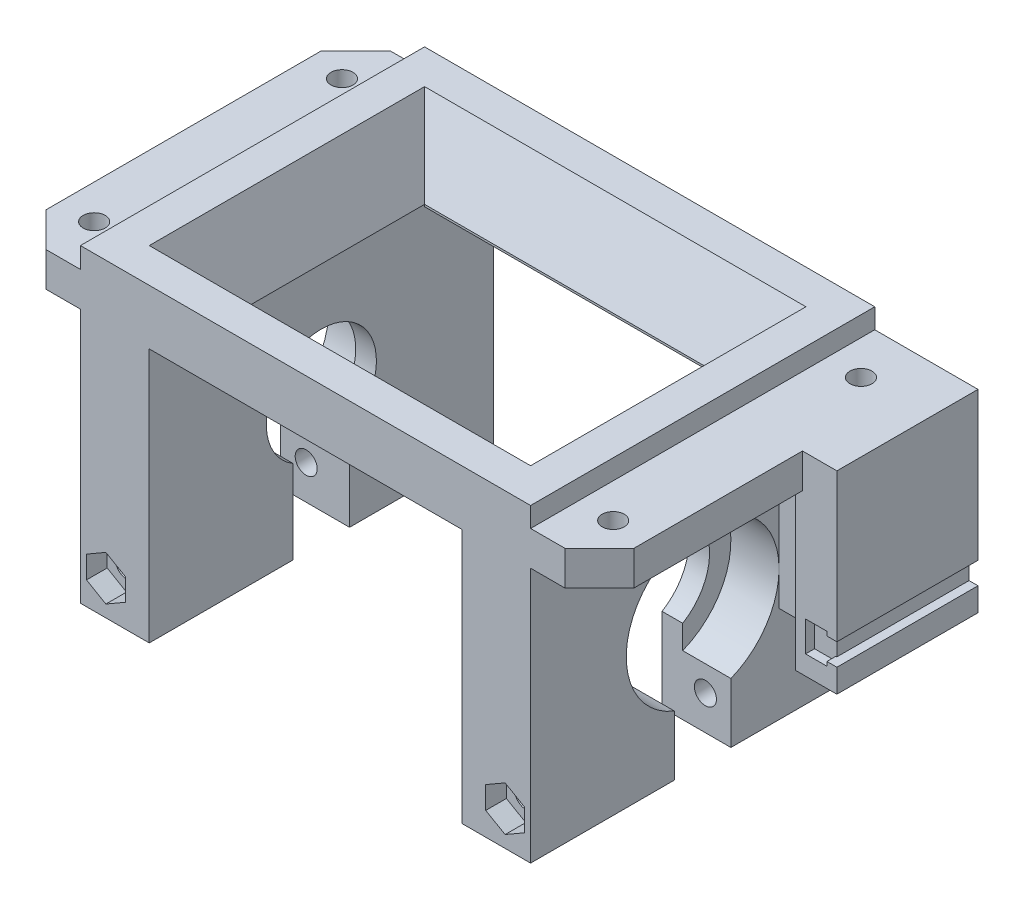
from build123d import *

# Parameters (mm, degrees)
SKETCH1_W           = 65.4
SKETCH1_H           = 60
SKETCH1_W_2         = 45.4
SKETCH1_H_2         = 30
BOSS_EXTRUDE1_DEPTH = 40
SKETCH2_R           = 8
CUT_EXTRUDE1_DEPTH  = 66.4
SKETCH3_W           = 45.4
SKETCH3_H           = 52
CUT_EXTRUDE2_DEPTH  = 37
CHAMFER1_SIZE       = 5
CHAMFER1_SIZE2      = 2.886751346
SKETCH7_W           = 65.4
SKETCH7_H           = 5
CUT_EXTRUDE5_DEPTH  = 41
CHAMFER2_SIZE       = 3
CHAMFER2_SIZE2      = 2.701212133
SKETCH8_W           = 65.4
SKETCH8_H           = 55
SKETCH8_W_2         = 45.4
SKETCH8_H_2         = 30
BOSS_EXTRUDE2_DEPTH = 10
CHAMFER3_SIZE       = 5
CHAMFER3_SIZE2      = 9.813052528
SKETCH10_R          = 11.1
CUT_EXTRUDE8_DEPTH  = 7
SKETCH11_R          = 11.1
CUT_EXTRUDE9_DEPTH  = 7
SKETCH12_W          = 65.4
SKETCH12_H          = 8.2
CUT_EXTRUDE10_DEPTH = 20
SKETCH13_W          = 65.4
SKETCH13_H          = 5
CUT_EXTRUDE11_DEPTH = 3
CHAMFER4_SIZE       = 5
SKETCH20_W          = 50
SKETCH20_H          = 5
BOSS_EXTRUDE5_DEPTH = 10
SKETCH21_W          = 50
SKETCH21_H          = 5
BOSS_EXTRUDE6_DEPTH = 10
CHAMFER5_SIZE       = 5
SKETCH23_R          = 1.6
CUT_EXTRUDE15_DEPTH = 48
SKETCH24_W          = 13.9
SKETCH24_H          = 10
BOSS_EXTRUDE7_DEPTH = 15
SKETCH22_R          = 1.6
CUT_EXTRUDE14_DEPTH = 48.107149008
SKETCH25_R          = 3.5
CUT_EXTRUDE16_DEPTH = 10
SKETCH27_W          = 6
SKETCH27_H          = 10
BOSS_EXTRUDE8_DEPTH = 6.6
CUT_EXTRUDE18_DEPTH = 1.3
SKETCH29_W          = 19.2
SKETCH29_H          = 3.2
CUT_EXTRUDE19_DEPTH = 1.3
SKETCH30_R          = 1.6
CUT_EXTRUDE20_DEPTH = 56
CUT_EXTRUDE21_DEPTH = 3
SKETCH32_R          = 3.15
CUT_EXTRUDE22_DEPTH = 5
SKETCH35_W          = 105.7739029
SKETCH35_H          = 101.810214422
CUT_EXTRUDE23_DEPTH = 5
CHAMFER6_SIZE       = 5
CUT_EXTRUDE25_DEPTH = 43
SKETCH37_R          = 3.5
BOSS_EXTRUDE9_DEPTH = 18.107149


with BuildPart() as part:
    # Sketch1 → Boss-Extrude1 (new body)
    with BuildSketch(Plane(origin=(0, 0, 0), x_dir=(1, 0, 0), z_dir=(0, 1, 0))):
        Rectangle(SKETCH1_W, SKETCH1_H)
        Rectangle(SKETCH1_W_2, SKETCH1_H_2, mode=Mode.SUBTRACT)
    extrude(amount=BOSS_EXTRUDE1_DEPTH)

    # Sketch2 → Cut-Extrude1 (cut, through all)
    with BuildSketch(Plane(origin=(32.7, 0, 0), x_dir=(0, 0, -1), z_dir=(1, 0, 0))):
        with Locations((0, 24)):
            Circle(SKETCH2_R)
    extrude(amount=-CUT_EXTRUDE1_DEPTH, mode=Mode.SUBTRACT)

    # Sketch3 → Cut-Extrude2 (cut)
    with BuildSketch(Plane.XZ):
        Rectangle(SKETCH3_W, SKETCH3_H)
    extrude(amount=-CUT_EXTRUDE2_DEPTH, mode=Mode.SUBTRACT)

    # Chamfer1
    chamfer1_edges = [part.edges().sort_by_distance(p)[0] for p in [
        (0, 37, -15),
    ]]
    chamfer1_side = [part.faces().sort_by_distance(p)[0] for p in [
        (0, 37, -20.5),
    ]]
    chamfer(chamfer1_edges, length=CHAMFER1_SIZE, length2=CHAMFER1_SIZE2, reference=chamfer1_side[0])

    # Sketch7 → Cut-Extrude5 (cut, through all)
    with BuildSketch(Plane(origin=(0, 40, 0), x_dir=(1, 0, 0), z_dir=(0, 1, 0))):
        with Locations((0, -27.5)):
            Rectangle(SKETCH7_W, SKETCH7_H)
    extrude(amount=-CUT_EXTRUDE5_DEPTH, mode=Mode.SUBTRACT)

    # Chamfer2
    chamfer2_edges = [part.edges().sort_by_distance(p)[0] for p in [
        (0, 37, 15),
    ]]
    chamfer2_side = [part.faces().sort_by_distance(p)[0] for p in [
        (0, 37, 20),
    ]]
    chamfer(chamfer2_edges, length=CHAMFER2_SIZE, length2=CHAMFER2_SIZE2, reference=chamfer2_side[0])

    # Sketch8 → Boss-Extrude2 (add)
    with BuildSketch(Plane(origin=(0, 40, 0), x_dir=(1, 0, 0), z_dir=(0, 1, 0))):
        with Locations((0, 2.5)):
            Rectangle(SKETCH8_W, SKETCH8_H)
        Rectangle(SKETCH8_W_2, SKETCH8_H_2, mode=Mode.SUBTRACT)
    extrude(amount=BOSS_EXTRUDE2_DEPTH)

    # Chamfer3
    chamfer3_edges = [part.edges().sort_by_distance(p)[0] for p in [
        (-22.7, 50, 0),
        (0, 50, 15),
        (22.7, 50, 0),
        (0, 50, -15),
    ]]
    chamfer3_side = [part.faces().sort_by_distance(p)[0] for p in [
        (0, 50, 24.14547323),
    ]]
    chamfer(chamfer3_edges, length=CHAMFER3_SIZE, length2=CHAMFER3_SIZE2, reference=chamfer3_side[0])

    # Sketch10 → Cut-Extrude8 (cut)
    with BuildSketch(Plane(origin=(32.7, 0, 0), x_dir=(0, 0, -1), z_dir=(1, 0, 0))):
        with Locations((0, 24)):
            Circle(SKETCH10_R)
    extrude(amount=-CUT_EXTRUDE8_DEPTH, mode=Mode.SUBTRACT)

    # Sketch11 → Cut-Extrude9 (cut)
    with BuildSketch(Plane.ZY.offset(32.7)):
        with Locations(Location((0, 24, 0), (0, 0, 180))):  # turned: the seam where the file's is
            Circle(SKETCH11_R)
    extrude(amount=-CUT_EXTRUDE9_DEPTH, mode=Mode.SUBTRACT)

    # Sketch12 → Cut-Extrude10 (cut)
    with BuildSketch(Plane.XZ):
        Rectangle(SKETCH12_W, SKETCH12_H)
    extrude(amount=-CUT_EXTRUDE10_DEPTH, mode=Mode.SUBTRACT)

    # Sketch13 → Cut-Extrude11 (cut)
    with BuildSketch(Plane(origin=(0, 50, 0), x_dir=(1, 0, 0), z_dir=(0, 1, 0))):
        with Locations((0, 27.5)):
            Rectangle(SKETCH13_W, SKETCH13_H)
    extrude(amount=-CUT_EXTRUDE11_DEPTH, mode=Mode.SUBTRACT)

    # Chamfer4
    chamfer4_edges = [part.edges().sort_by_distance(p)[0] for p in [
        (-32.7, 23.5, -30),
        (32.7, 23.5, -30),
    ]]
    chamfer(chamfer4_edges, length=CHAMFER4_SIZE)

    # Sketch20 → Boss-Extrude5 (add)
    with BuildSketch(Plane(origin=(32.7, 0, 0), x_dir=(0, 0, -1), z_dir=(1, 0, 0))):
        with Locations((0, 44.607149008)):
            Rectangle(SKETCH20_W, SKETCH20_H)
    extrude(amount=BOSS_EXTRUDE5_DEPTH)

    # Sketch21 → Boss-Extrude6 (add)
    with BuildSketch(Plane.ZY.offset(32.7)):
        with Locations((0, 44.5)):
            Rectangle(SKETCH21_W, SKETCH21_H)
    extrude(amount=BOSS_EXTRUDE6_DEPTH)

    # Chamfer5
    chamfer5_edges = [part.edges().sort_by_distance(p)[0] for p in [
        (42.7, 44.607149008, 25),
        (42.7, 44.607149008, -25),
        (-42.7, 44.5, -25),
        (-42.7, 44.5, 25),
    ]]
    chamfer(chamfer5_edges, length=CHAMFER5_SIZE)

    # Sketch23 → Cut-Extrude15 (cut, through all)
    with BuildSketch(Plane(origin=(0, 47, 0), x_dir=(1, 0, 0), z_dir=(0, 1, 0))):
        with Locations(Location((-37.7, 18, 0), (0, 0, 270))):  # turned: the seam where the file's is
            Circle(SKETCH23_R)
        with Locations(Location((-37.7, -18, 0), (0, 0, 270))):  # turned: the seam where the file's is
            Circle(SKETCH23_R)
    extrude(amount=-CUT_EXTRUDE15_DEPTH, mode=Mode.SUBTRACT)

    # Sketch24 → Boss-Extrude7 (add)
    with BuildSketch(Plane(origin=(32.7, 0, 0), x_dir=(0, 0, -1), z_dir=(1, 0, 0))):
        with Locations((18.05, 24)):
            Rectangle(SKETCH24_W, SKETCH24_H)
    extrude(amount=BOSS_EXTRUDE7_DEPTH)

    # Sketch22 → Cut-Extrude14 (cut, through all)
    with BuildSketch(Plane(origin=(0, 47.107149008, 0), x_dir=(1, 0, 0), z_dir=(0, 1, 0))):
        with Locations(Location((37.7, -18, 0), (0, 0, 270))):  # turned: the seam where the file's is
            Circle(SKETCH22_R)
        with Locations(Location((37.7, 18, 0), (0, 0, 270))):  # turned: the seam where the file's is
            Circle(SKETCH22_R)
    extrude(amount=-CUT_EXTRUDE14_DEPTH, mode=Mode.SUBTRACT)

    # Sketch25 → Cut-Extrude16 (cut)
    with BuildSketch(Plane.XZ.offset(-19)):
        with Locations(Location((37.7, -18, 0), (0, 0, 270))):  # turned: the seam where the file's is
            Circle(SKETCH25_R)
    extrude(amount=-CUT_EXTRUDE16_DEPTH, mode=Mode.SUBTRACT)

    # Sketch27 → Boss-Extrude8 (add)
    with BuildSketch(Plane.XY.offset(-11.1)):
        with Locations((44.7, 24)):
            Rectangle(SKETCH27_W, SKETCH27_H)
    extrude(amount=BOSS_EXTRUDE8_DEPTH)

    # Sketch28 → Cut-Extrude18 (cut)
    with BuildSketch(Plane.XY.offset(-4.5)):
        Polygon((46.25, 21.8), (46.25, 22.4), (47.7, 22.4), (47.7, 25.6), (46.25, 25.6), (46.25, 26.2), (43.15, 26.2), (43.15, 21.8), align=None)
    extrude(amount=-CUT_EXTRUDE18_DEPTH, mode=Mode.SUBTRACT)

    # Sketch29 → Cut-Extrude19 (cut)
    with BuildSketch(Plane(origin=(47.7, 0, 0), x_dir=(0, 0, -1), z_dir=(1, 0, 0))):
        with Locations((15.4, 24)):
            Rectangle(SKETCH29_W, SKETCH29_H)
    extrude(amount=-CUT_EXTRUDE19_DEPTH, mode=Mode.SUBTRACT)

    # Sketch30 → Cut-Extrude20 (cut, through all)
    with BuildSketch(Plane.XY.offset(25)):
        with Locations(Location((-29, 10, 0), (0, 0, 324.340912304))):  # turned: the seam where the file's is
            Circle(SKETCH30_R)
        with Locations(Location((29, 10, 0), (0, 0, 144.340912304))):  # turned: the seam where the file's is
            Circle(SKETCH30_R)
    extrude(amount=-CUT_EXTRUDE20_DEPTH, mode=Mode.SUBTRACT)

    # Sketch31 → Cut-Extrude21 (cut)
    with BuildSketch(Plane.XY.offset(25)):
        Polygon((26.185417438, 11.625), (26.185417438, 8.375), (29, 6.75), (31.814582562, 8.375), (31.814582562, 11.625), (29, 13.25), align=None)
        Polygon((-31.814582562, 11.625), (-31.814582562, 8.375), (-29, 6.75), (-26.185417438, 8.375), (-26.185417438, 11.625), (-29, 13.25), align=None)
    extrude(amount=-CUT_EXTRUDE21_DEPTH, mode=Mode.SUBTRACT)

    # Sketch32 → Cut-Extrude22 (cut)
    with BuildSketch(Plane(origin=(0, 0, -30), x_dir=(-1, 0, 0), z_dir=(0, 0, -1))):
        with Locations((-29, 10)):
            Circle(SKETCH32_R)
        with Locations((29, 10)):
            Circle(SKETCH32_R)
    extrude(amount=-CUT_EXTRUDE22_DEPTH, mode=Mode.SUBTRACT)

    # Sketch35 → Cut-Extrude23 (cut)
    with BuildSketch(Plane.XZ):
        Rectangle(SKETCH35_W, SKETCH35_H)
    extrude(amount=-CUT_EXTRUDE23_DEPTH, mode=Mode.SUBTRACT)

    # Chamfer6
    chamfer6_edges = [part.edges().sort_by_distance(p)[0] for p in [
        (0, 37, 25),
    ]]
    chamfer(chamfer6_edges, length=CHAMFER6_SIZE)

    # Sketch36 → Cut-Extrude25 (cut, through all)
    with BuildSketch(Plane(origin=(0, 47, 0), x_dir=(1, 0, 0), z_dir=(0, 1, 0))):
        Polygon((32.7, 25), (27.7, 30), (-27.7, 30), (-32.7, 25), align=None)
    extrude(amount=-CUT_EXTRUDE25_DEPTH, mode=Mode.SUBTRACT)

    # Sketch37 → Boss-Extrude9 (add)
    with BuildSketch(Plane(origin=(0, 29, 0), x_dir=(1, 0, 0), z_dir=(0, 1, 0))):
        Polygon((32.7, 11.1), (41.7, 11.1), (41.7, 4.5), (47.7, 4.5), (47.7, 25), (32.7, 25), align=None)
        with Locations(Location((37.7, 18, 0), (0, 0, 90))):  # turned: the seam where the file's is
            Circle(SKETCH37_R, mode=Mode.SUBTRACT)
    extrude(amount=BOSS_EXTRUDE9_DEPTH)


solid = part.part
